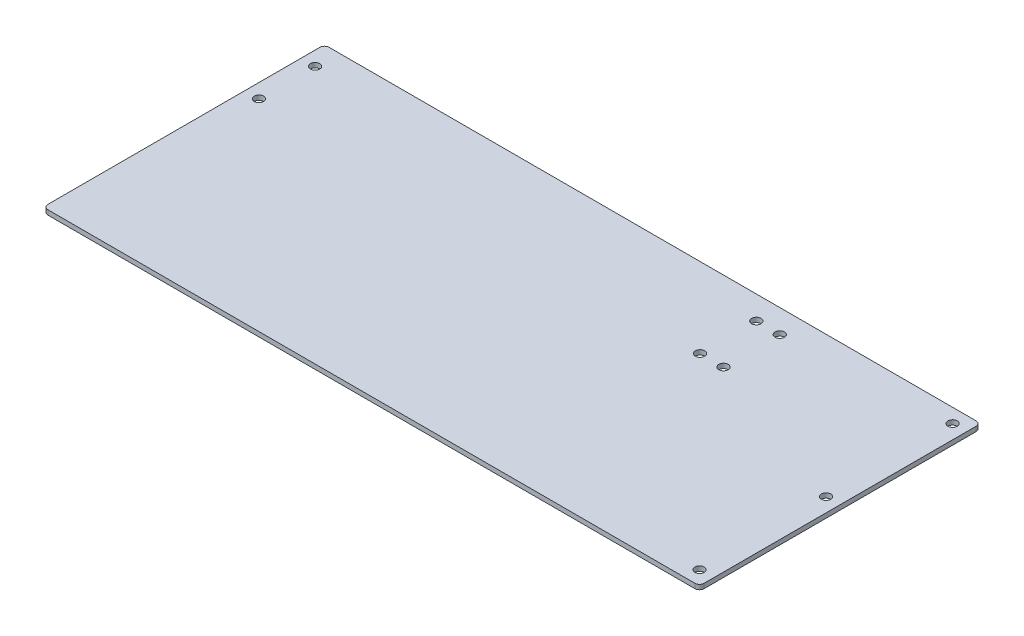
from build123d import *

# Parameters (mm, degrees)
SKETCH1_W                   = 444.5
SKETCH1_H                   = 190.5
BOSS_EXTRUDE1_DEPTH         = 3.175
F_1_4_0_25_DIAMETER_HOLE1_D = 6.35
FILLET1_R                   = 3.175
F_1_4_0_25_DIAMETER_HOLE2_D = 6.35


with BuildPart() as part:
    # Sketch1 → Boss-Extrude1 (new body)
    with BuildSketch(Plane(origin=(0, 0, 0), x_dir=(1, 0, 0), z_dir=(0, 1, 0))):
        Rectangle(SKETCH1_W, SKETCH1_H)
    extrude(amount=BOSS_EXTRUDE1_DEPTH)

    # 1/4 (0.25) Diameter Hole1 (through all)
    with Locations(Plane(origin=(0, 3.175, 0), x_dir=(1, 0, 0), z_dir=(0, 1, 0))):
        with Locations((-212.725, 79.375), (-212.725, 41.275), (101.981, 79.375), (101.981, 41.275), (86.106, 79.375), (86.106, 41.275)):
            Hole(F_1_4_0_25_DIAMETER_HOLE1_D / 2)

    # Fillet1
    fillet1_edges = [part.edges().sort_by_distance(p)[0] for p in [
        (222.25, 1.5875, 95.25),
        (-222.25, 1.5875, 95.25),
        (-222.25, 1.5875, -95.25),
        (222.25, 1.5875, -95.25),
    ]]
    fillet(fillet1_edges, radius=FILLET1_R)

    # 1/4 (0.25) Diameter Hole2 (through all)
    with Locations(Plane(origin=(0, 0, 0), x_dir=(-1, 0, 0), z_dir=(0, -1, 0))):
        with Locations((-212.725, 85.725), (-212.725, 0), (-212.725, -85.725)):
            Hole(F_1_4_0_25_DIAMETER_HOLE2_D / 2)


solid = part.part
